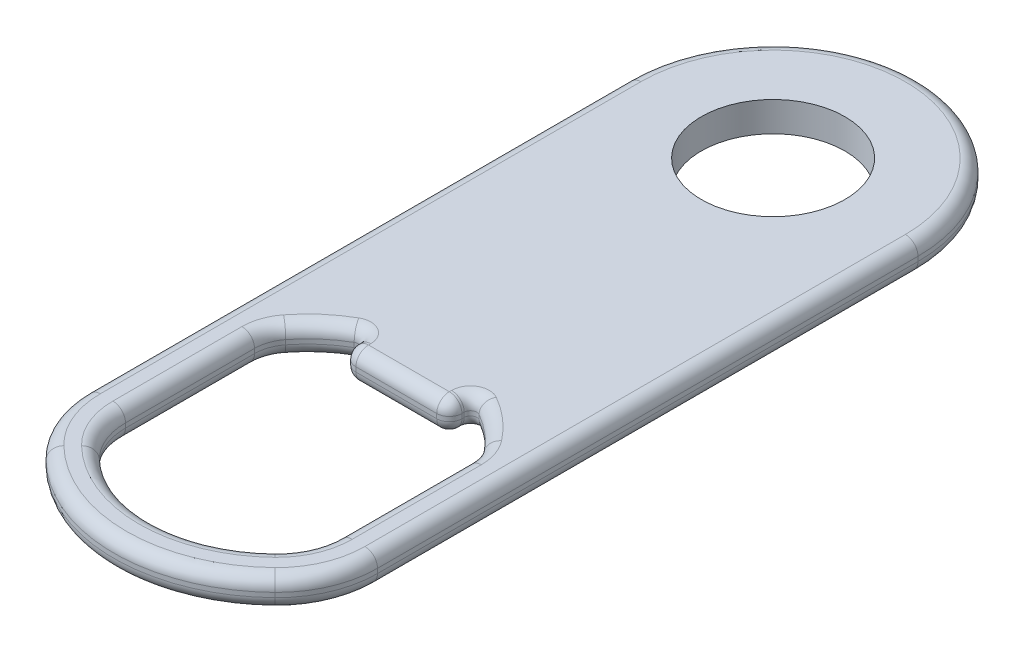
from build123d import *

# Parameters (mm, degrees)
BOSS_EXTRUDE1_DEPTH = 2.36
CUT_EXTRUDE1_DEPTH  = 10
FILLET1_R           = 1
FILLET2_R           = 8
FILLET3_R           = 5
FILLET4_R           = 3
FILLET5_R           = 0.5
FILLET6_R           = 1
FILLET7_R           = 1


with BuildPart() as part:
    # Sketch3 → Boss-Extrude1 (new body)
    with BuildSketch(Plane(origin=(0, 10.92, 0), x_dir=(0, 0, 1), z_dir=(0, -1, 0))):
        with BuildLine():
            Line((-5.7, 0), (-12.000001825, 0))
            Line((-12.000001825, 0), (-12.000001825, 11.5))
            Line((-12.000001825, 11.5), (45.406310527, 11.5))
            ThreePointArc((45.406310527, 11.5), (50.46030749, 6.709778353), (52.322559669, 0))
            Line((52.322559669, 0), (49.322559669, 0))
            ThreePointArc((49.322559669, 0), (48.068036881, 4.857481326), (44.618252316, 8.499999508))
            Line((44.618252316, 8.499999508), (31.732809444, 8.499999508))
            ThreePointArc((31.732809444, 8.499999508), (29.503647996, 6.63570395), (27.906627074, 4.207889529))
            Line((27.906627074, 4.207889529), (29.906623676, 4.207889529))
            Line((29.906623676, 4.207889529), (29.906623676, 0))
            Line((29.906623676, 0), (5.7, 0))
            ThreePointArc((5.7, 0), (0, 5.7), (-5.7, 0))
        make_face()
    extrude(amount=-BOSS_EXTRUDE1_DEPTH)

    # Sketch5 → Cut-Extrude1 (cut)
    with BuildSketch(Plane(origin=(0, 10.92, 0), x_dir=(0, 0, 1), z_dir=(0, -1, 0))):
        with BuildLine():
            Line((0, 11.5), (0, 20.081542109))
            Line((0, 20.081542109), (-17.206571574, 20.081542109))
            Line((-17.206571574, 20.081542109), (-17.206571574, -3.325861619))
            Line((-17.206571574, -3.325861619), (-11.00857141, -3.325861619))
            ThreePointArc((-11.00857141, -3.325861619), (-9.23302249, 6.855749098), (0, 11.5))
        make_face()
    extrude(amount=-CUT_EXTRUDE1_DEPTH, mode=Mode.SUBTRACT)

    # Fillet1
    fillet1_edges = [part.edges().sort_by_distance(p)[0] for p in [
        (-4.207889529, 12.1, 29.906623676),
    ]]
    fillet(fillet1_edges, radius=FILLET1_R)

    # Fillet2
    fillet2_edges = [part.edges().sort_by_distance(p)[0] for p in [
        (-11.5, 12.1, 45.406310527),
    ]]
    fillet(fillet2_edges, radius=FILLET2_R)

    # Fillet3
    fillet3_edges = [part.edges().sort_by_distance(p)[0] for p in [
        (-8.499999508, 12.1, 44.618252316),
    ]]
    fillet(fillet3_edges, radius=FILLET3_R)

    # Fillet4
    fillet4_edges = [part.edges().sort_by_distance(p)[0] for p in [
        (-8.499999508, 12.1, 31.732809444),
    ]]
    fillet(fillet4_edges, radius=FILLET4_R)

    # Fillet5
    fillet5_edges = [part.edges().sort_by_distance(p)[0] for p in [
        (-4.207889529, 12.1, 27.906627074),
    ]]
    fillet(fillet5_edges, radius=FILLET5_R)

    # Fillet6
    fillet6_edges = [part.edges().sort_by_distance(p)[0] for p in [
        (-4.899665378, 10.92, 51.36538086),
        (-8.131727984, 10.92, -8.131727984),
        (-4.899665378, 13.28, 51.36538086),
        (-8.131727984, 13.28, -8.131727984),
        (-11.5, 10.92, 21.45040417),
        (-10.869902111, 10.92, 46.012808159),
        (-11.5, 13.28, 21.45040417),
        (-10.869902111, 13.28, 46.012808159),
    ]]
    fillet(fillet6_edges, radius=FILLET6_R)

    # Fillet7
    fillet7_edges = [part.edges().sort_by_distance(p)[0] for p in [
        (-1.603944764, 13.28, 29.906623676),
        (-1.603944764, 10.92, 29.906623676),
        (-4.207889529, 10.92, 28.817398931),
        (-3.91499631, 10.92, 29.613730457),
        (-4.207889529, 13.28, 28.817398931),
        (-3.91499631, 13.28, 29.613730457),
        (-3.764181528, 10.92, 48.589533472),
        (-3.764181528, 13.28, 48.589533472),
        (-8.103866337, 10.92, 44.856156934),
        (-8.103866337, 13.28, 44.856156934),
        (-8.499999508, 13.28, 37.784126486),
        (-8.499999508, 10.92, 37.784126486),
        (-8.337232062, 10.92, 31.68784918),
        (-8.337232062, 13.28, 31.68784918),
        (-6.534576313, 13.28, 29.414716402),
        (-6.534576313, 10.92, 29.414716402),
        (-4.457147388, 10.92, 28.295590808),
        (-4.457147388, 13.28, 28.295590808),
    ]]
    fillet(fillet7_edges, radius=FILLET7_R)

    # Mirror1: part across plane


with BuildPart() as part_1:
    add(part.part)
    add(part.part.mirror(Plane(origin=(0, 0, 0), x_dir=(0, 0, 1), z_dir=(1, 0, 0))))


solid = part_1.part
